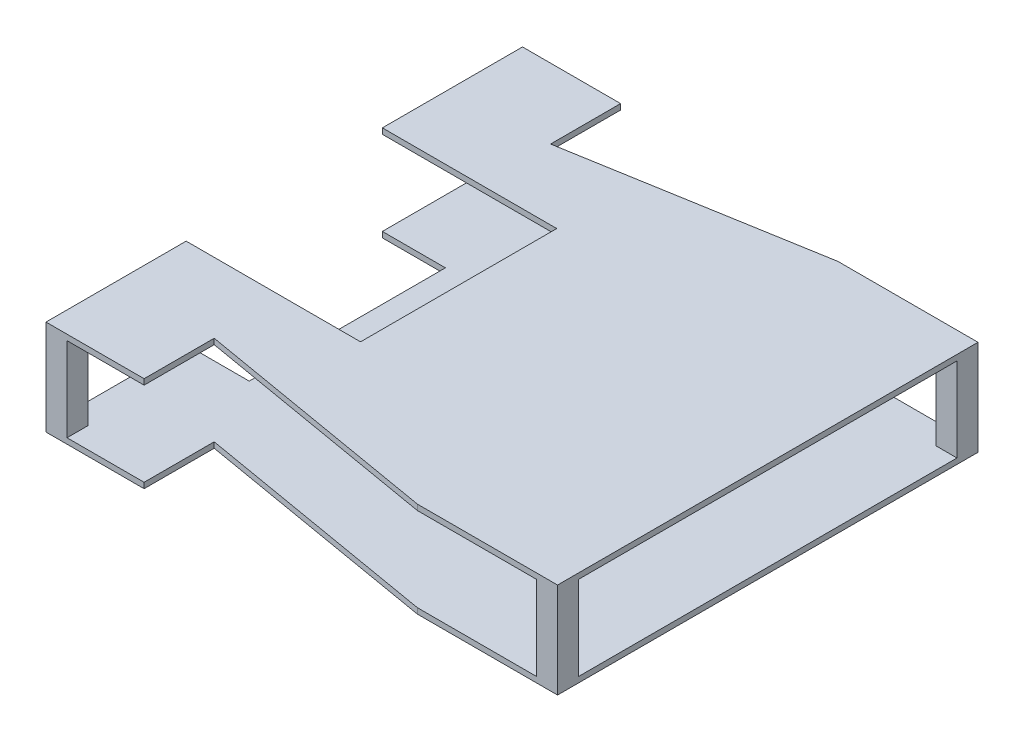
from build123d import *

# Parameters (mm, degrees)
BOSS_EXTRUDE1_DEPTH = 2
SKETCH3_W           = 7.5
SKETCH3_H           = 7.5
BOSS_EXTRUDE2_DEPTH = 30
BOSS_EXTRUDE3_DEPTH = 2


with BuildPart() as part:
    # Sketch2 → Boss-Extrude1 (new body)
    with BuildSketch(Plane(origin=(0, 0, 0), x_dir=(1, 0, 0), z_dir=(0, 1, 0))):
        Polygon((0, 35), (0, -35), (-22.5, -35), (-22.5, -85), (12.5, -85), (12.5, -60), (100, -75), (150, -75), (150, 75), (100.180900235, 75), (12.680900235, 60), (12.5, 60), (12.5, 85), (-22.5, 85), (-22.5, 35), align=None)
    extrude(amount=BOSS_EXTRUDE1_DEPTH)

    # Sketch3 → Boss-Extrude2 (add)
    with BuildSketch(Plane(origin=(0, 2, 0), x_dir=(1, 0, 0), z_dir=(0, 1, 0))):
        with Locations((146.25, 71.25)):
            Rectangle(SKETCH3_W, SKETCH3_H)
        with Locations((146.25, -71.25)):
            Rectangle(SKETCH3_W, SKETCH3_H)
        with Locations((-18.75, 81.25)):
            Rectangle(SKETCH3_W, SKETCH3_H)
        with Locations((-18.75, -81.25)):
            Rectangle(SKETCH3_W, SKETCH3_H)
    extrude(amount=BOSS_EXTRUDE2_DEPTH)

    # Sketch5 → Boss-Extrude3 (add)
    with BuildSketch(Plane(origin=(0, 32, 0), x_dir=(1, 0, 0), z_dir=(0, 1, 0))):
        Polygon((150, 75), (100, 75), (12.5, 60), (12.5, 85), (-22.5, 85), (-22.5, 65), (-22.5, 35), (39.717843368, 35), (39.717843368, -35), (-22.5, -35), (-22.5, -85), (12.5, -85), (12.5, -60), (100, -75), (150, -75), align=None)
    extrude(amount=BOSS_EXTRUDE3_DEPTH)


solid = part.part
